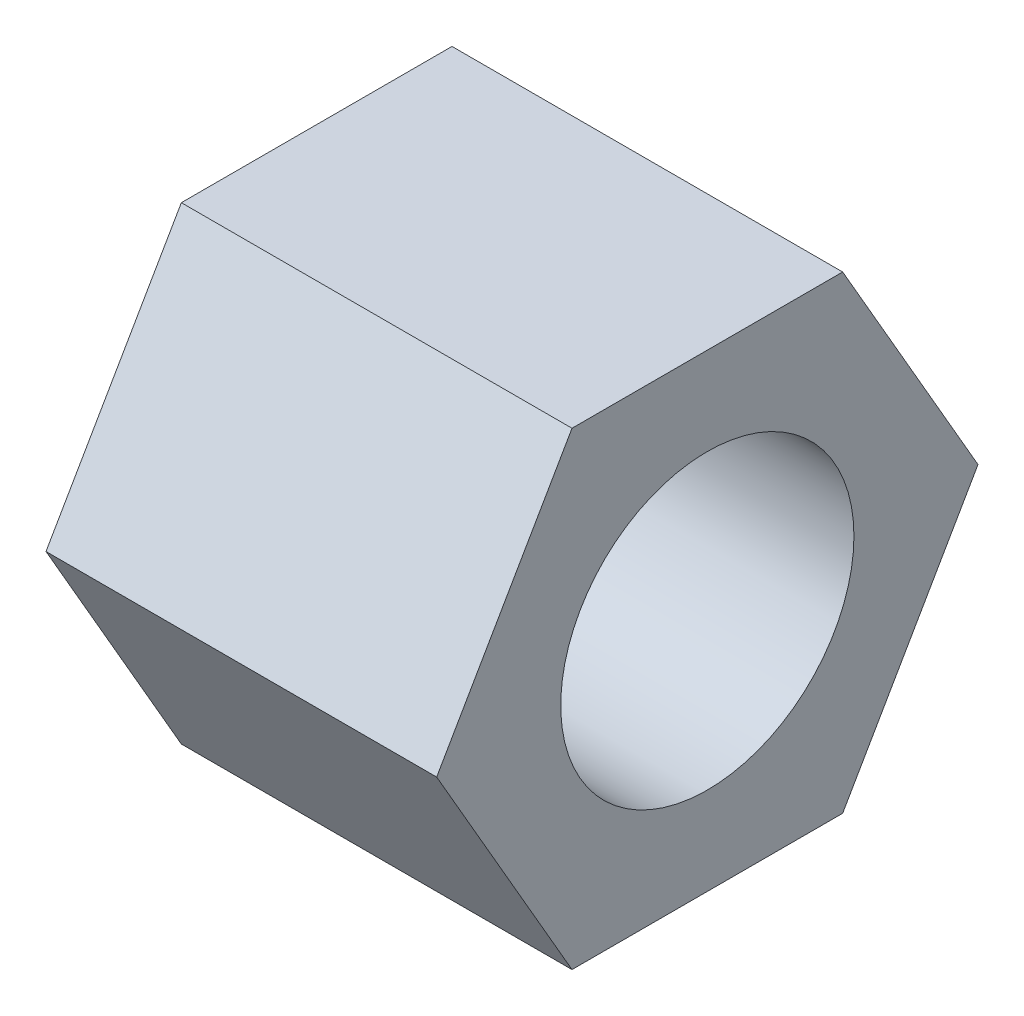
from build123d import *

# Parameters (mm, degrees)
EXTRUDE_1_DEPTH     = 10
SKETCH_2_R          = 3.75277675
CUT_EXTRUDE_1_DEPTH = 8
SKETCH_3_R          = 1.5
CUT_EXTRUDE_2_DEPTH = 7


with BuildPart() as part:
    # 草图1 → 凸台-拉伸1 (new body)
    with BuildSketch(Plane(origin=(0, 0, 0), x_dir=(0, 0, -1), z_dir=(1, 0, 0))):
        Polygon((6.92820323, 0), (3.464101615, 6), (-3.464101615, 6), (-6.92820323, 0), (-3.464101615, -6), (3.464101615, -6), align=None)
    extrude(amount=EXTRUDE_1_DEPTH)

    # 草图2 → 切除-拉伸1 (cut)
    with BuildSketch(Plane(origin=(10, 0, 0), x_dir=(0, 0, -1), z_dir=(1, 0, 0))):
        Circle(SKETCH_2_R)
    extrude(amount=-CUT_EXTRUDE_1_DEPTH, mode=Mode.SUBTRACT)

    # 草图3 → 切除-拉伸2 (cut)
    with BuildSketch(Plane(origin=(2, 0, 0), x_dir=(0, 0, -1), z_dir=(1, 0, 0))):
        Circle(SKETCH_3_R)
    extrude(amount=-CUT_EXTRUDE_2_DEPTH, mode=Mode.SUBTRACT)


solid = part.part
